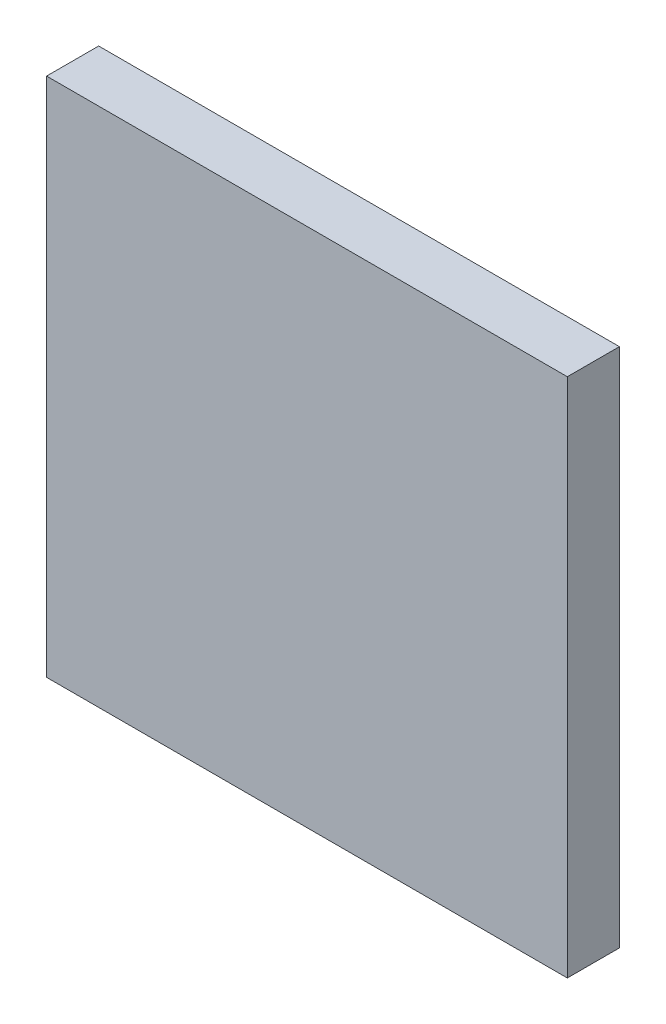
from build123d import *

# Parameters (mm, degrees)
ESBO_O1_W                = 10
ESBO_O1_H                = 10
RESSALTO_EXTRUS_O1_DEPTH = 1


with BuildPart() as part:
    # Esboço1 → Ressalto-extrusão1 (new body)
    with BuildSketch(Plane.XY):
        with Locations((5, 5)):
            Rectangle(ESBO_O1_W, ESBO_O1_H)
    extrude(amount=RESSALTO_EXTRUS_O1_DEPTH)


solid = part.part
